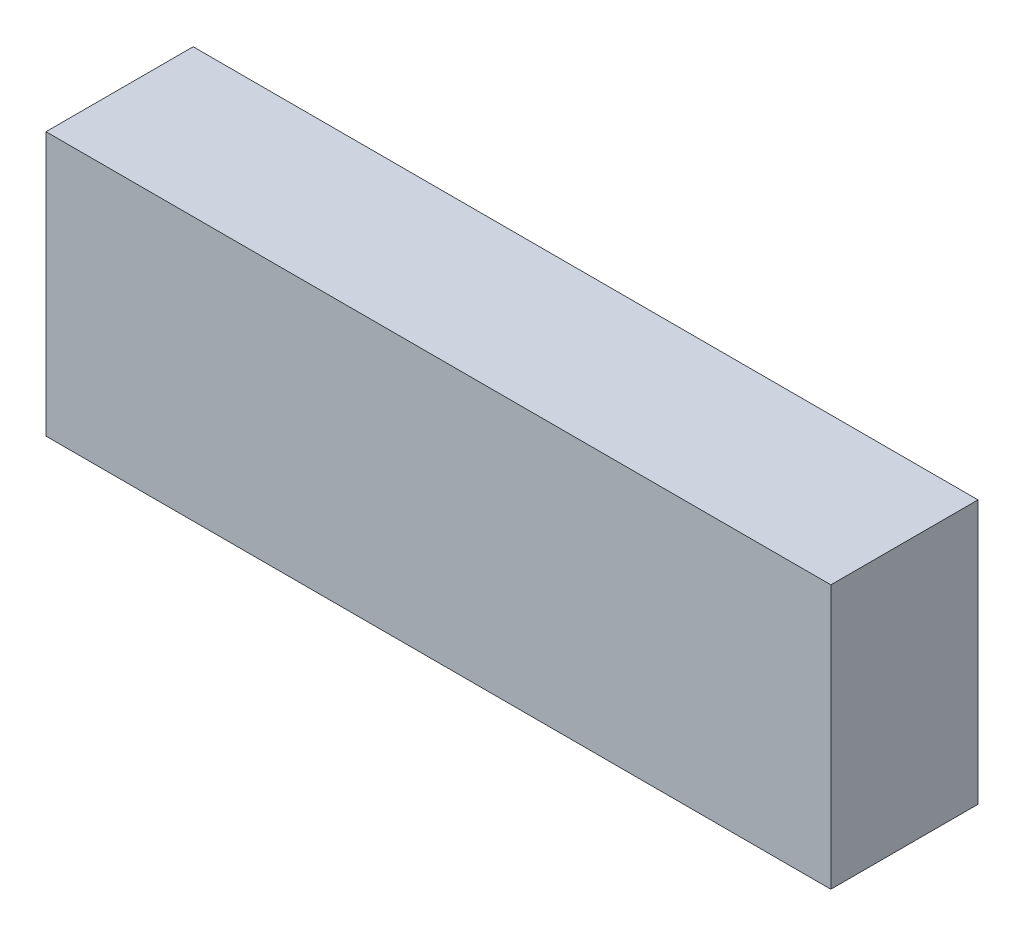
from build123d import *

# Parameters (mm, degrees)
SKETCH_1_W      = 128
SKETCH_1_H      = 43
EXTRUDE_1_DEPTH = 24


with BuildPart() as part:
    # 草图1 → 凸台-拉伸1 (new body)
    with BuildSketch(Plane.XY):
        Rectangle(SKETCH_1_W, SKETCH_1_H)
    extrude(amount=EXTRUDE_1_DEPTH)


solid = part.part
